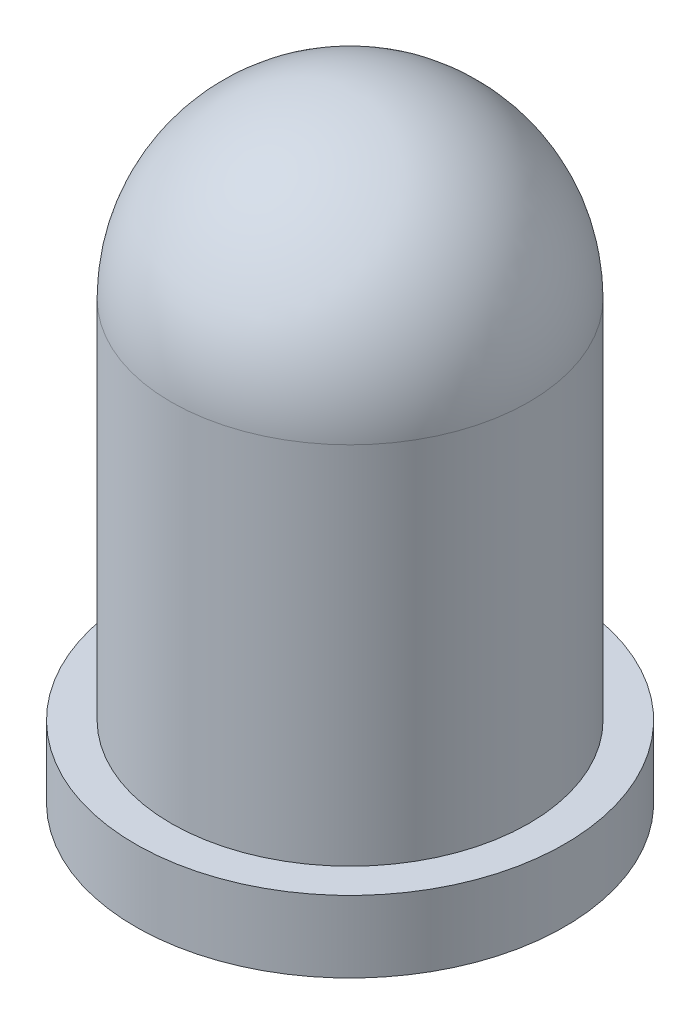
from build123d import *


with BuildPart() as part:
    # Sketch1 → Revolve3 (revolve)
    with BuildSketch(Plane.XY):
        with BuildLine():
            Line((0, 0), (-3, 0))
            Line((-3, 0), (-3, 1))
            Line((-3, 1), (-2.5, 1))
            Line((-2.5, 1), (-2.5, 6.1))
            ThreePointArc((-2.5, 6.1), (-1.767766953, 7.867766953), (0, 8.6))
            Line((0, 8.6), (0, 6.1))
            Line((0, 6.1), (0, 0))
        make_face()
    revolve(axis=Axis((0, 6.1, 0), (0, -1, 0)))


solid = part.part
